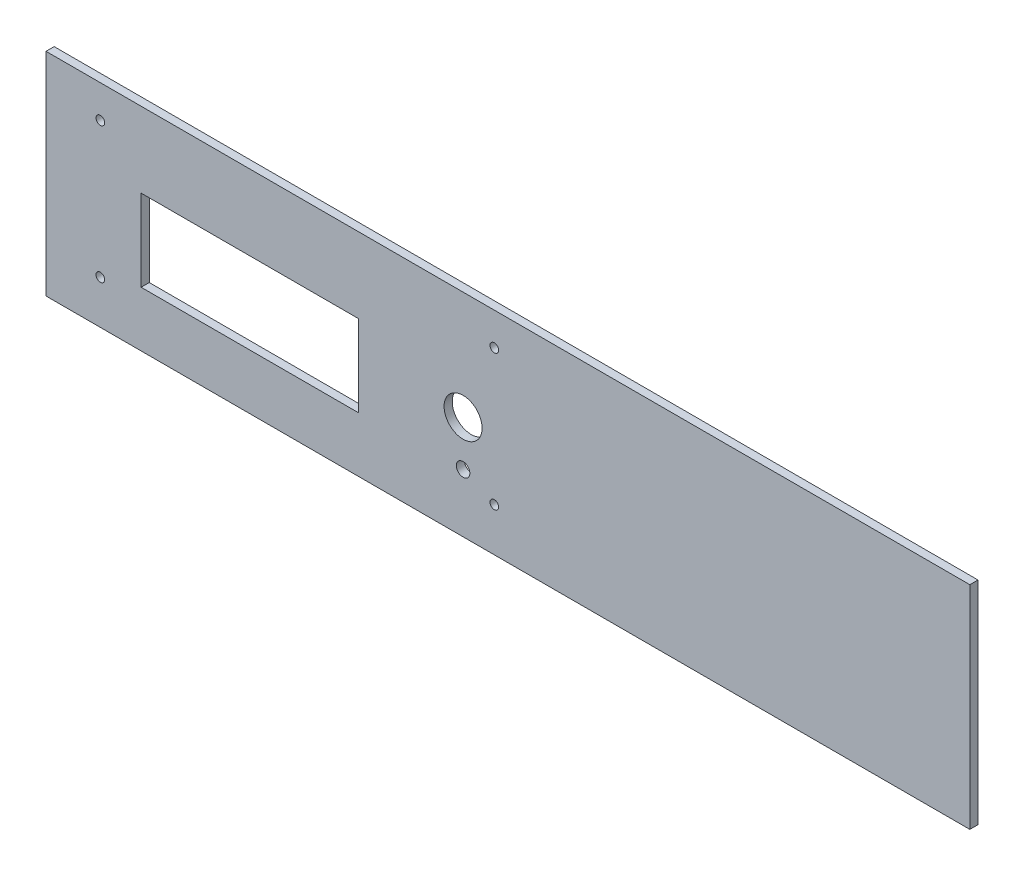
from build123d import *

# Parameters (mm, degrees)
ESQUISSE1_W             = 340
ESQUISSE1_H             = 78
BOSS_EXTRU_1_DEPTH      = 3
ESQUISSE2_R             = 1.6
ENL_V_MAT_EXTRU_1_DEPTH = 4
ESQUISSE3_W             = 80
ESQUISSE3_H             = 30
ENL_V_MAT_EXTRU_2_DEPTH = 4
ESQUISSE4_R             = 7
ESQUISSE4_R_2           = 2.5
ENL_V_MAT_EXTRU_3_DEPTH = 4


with BuildPart() as part:
    # Esquisse1 → Boss.-Extru.1 (new body)
    with BuildSketch(Plane.XY):
        Rectangle(ESQUISSE1_W, ESQUISSE1_H)
    extrude(amount=BOSS_EXTRU_1_DEPTH)

    # Esquisse2 → Enlèv. mat.-Extru.1 (cut, through all)
    with BuildSketch(Plane.XY.offset(3)):
        with Locations((-150, 27)):
            Circle(ESQUISSE2_R)
        with Locations((-150, -23)):
            Circle(ESQUISSE2_R)
        with Locations((-5, 27)):
            Circle(ESQUISSE2_R)
        with Locations((-5, -23)):
            Circle(ESQUISSE2_R)
    extrude(amount=-ENL_V_MAT_EXTRU_1_DEPTH, mode=Mode.SUBTRACT)

    # Esquisse3 → Enlèv. mat.-Extru.2 (cut, through all)
    with BuildSketch(Plane.XY.offset(3)):
        with Locations((-95, -3.7)):
            Rectangle(ESQUISSE3_W, ESQUISSE3_H)
    extrude(amount=-ENL_V_MAT_EXTRU_2_DEPTH, mode=Mode.SUBTRACT)

    # Esquisse4 → Enlèv. mat.-Extru.3 (cut, through all)
    with BuildSketch(Plane.XY.offset(3)):
        with Locations((-16.5, -0.9)):
            Circle(ESQUISSE4_R)
        with Locations((-16.5, -17.5)):
            Circle(ESQUISSE4_R_2)
    extrude(amount=-ENL_V_MAT_EXTRU_3_DEPTH, mode=Mode.SUBTRACT)


solid = part.part
